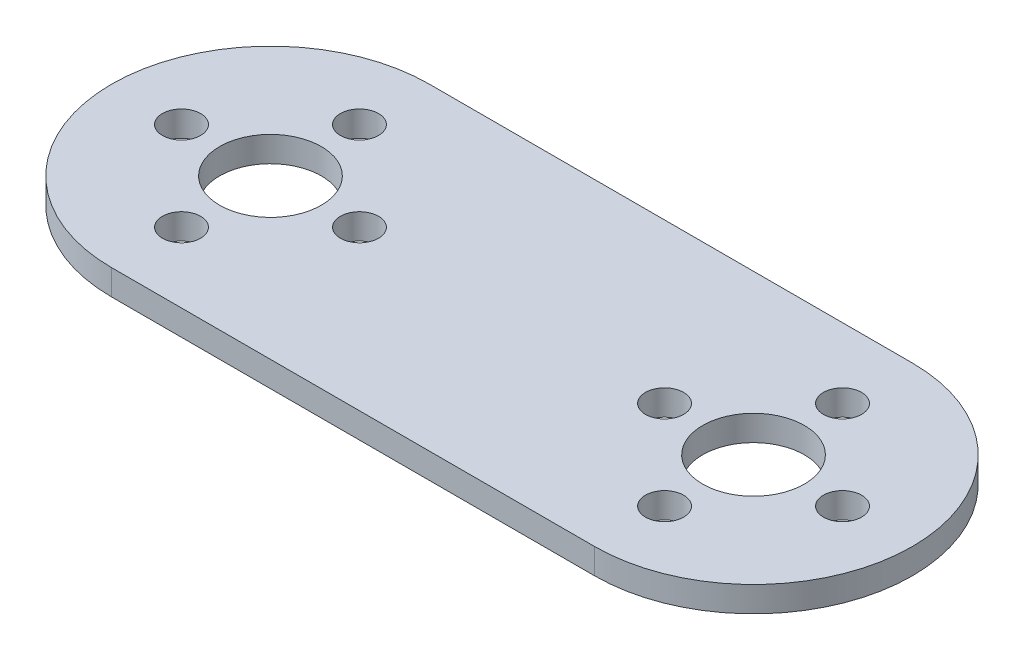
from build123d import *

# Parameters (mm, degrees)
SKETCH1_R           = 4
SKETCH1_R_2         = 1.5
BOSS_EXTRUDE1_DEPTH = 2


with BuildPart() as part:
    # Sketch1 → Boss-Extrude1 (new body)
    with BuildSketch(Plane(origin=(0, 0, 0), x_dir=(1, 0, 0), z_dir=(0, 1, 0))):
        with BuildLine():
            Line((19, -12.5), (-19, -12.5))
            ThreePointArc((-19, -12.5), (-31.5, 0), (-19, 12.5))
            Line((-19, 12.5), (19, 12.5))
            ThreePointArc((19, 12.5), (31.5, 0), (19, -12.5))
        make_face()
        with Locations((-19, 0)):
            Circle(SKETCH1_R, mode=Mode.SUBTRACT)
        with Locations((19, 0)):
            Circle(SKETCH1_R, mode=Mode.SUBTRACT)
        with Locations((-19, 7)):
            Circle(SKETCH1_R_2, mode=Mode.SUBTRACT)
        with Locations((-12, 0)):
            Circle(SKETCH1_R_2, mode=Mode.SUBTRACT)
        with Locations((-26, 0)):
            Circle(SKETCH1_R_2, mode=Mode.SUBTRACT)
        with Locations((-19, -7)):
            Circle(SKETCH1_R_2, mode=Mode.SUBTRACT)
        with Locations((12, 0)):
            Circle(SKETCH1_R_2, mode=Mode.SUBTRACT)
        with Locations((19, 7)):
            Circle(SKETCH1_R_2, mode=Mode.SUBTRACT)
        with Locations((26, 0)):
            Circle(SKETCH1_R_2, mode=Mode.SUBTRACT)
        with Locations((19, -7)):
            Circle(SKETCH1_R_2, mode=Mode.SUBTRACT)
    extrude(amount=BOSS_EXTRUDE1_DEPTH)


solid = part.part
